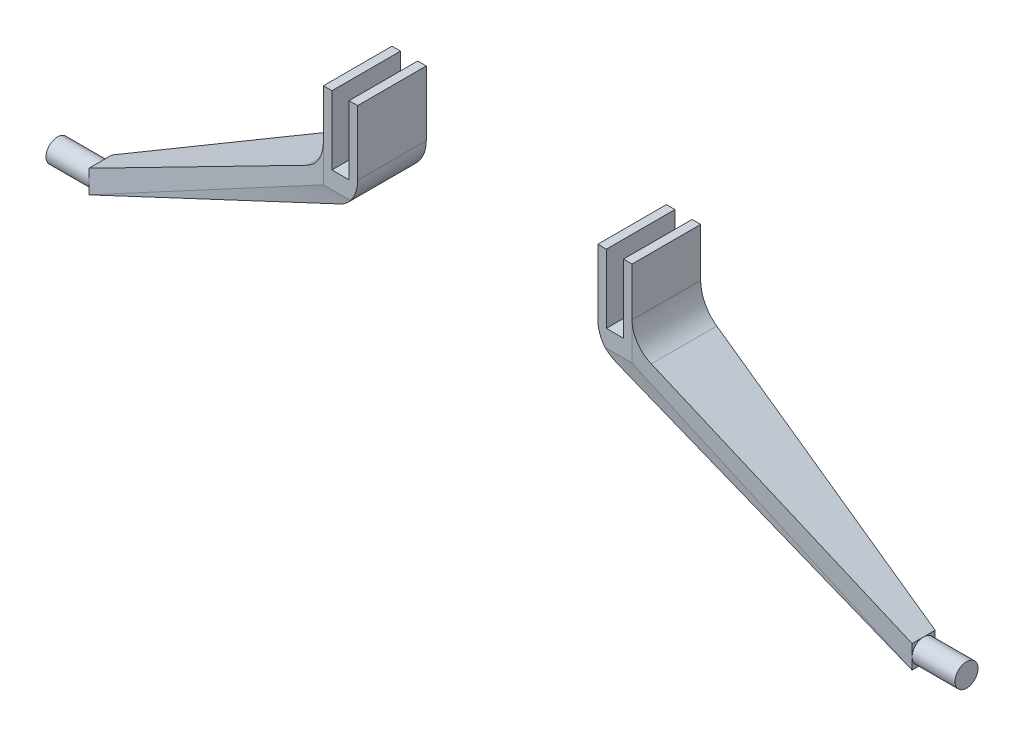
from build123d import *

# Parameters (mm, degrees)
BOSS_EXTRUDE1_DEPTH = 25.4
FILLET2_R           = 12.7
FILLET3_R           = 12.7
SKETCH7_R           = 4.2625
BOSS_EXTRUDE3_DEPTH = 15.875


with BuildPart() as part:
    # Sketch3 → Boss-Extrude1 (new body)
    with BuildSketch(Plane.XY):
        Polygon((-44.45, 50.8), (-44.45, 82.55), (-47.625, 82.55), (-47.625, 57.15), (-53.975, 57.15), (-53.975, 82.55), (-57.15, 82.55), (-57.15, 50.8), align=None)
    extrude(amount=BOSS_EXTRUDE1_DEPTH)

    # Sketch5 → section 1 of loft1
    with BuildSketch(Plane(origin=(-152.4, 0, 0), x_dir=(0, 0, -1), z_dir=(1, 0, 0)), mode=Mode.PRIVATE) as loft1_s1:
        with BuildLine():
            Line((-16.9625, 4.2625), (-8.4375, 4.2625))
            Line((-8.4375, 4.2625), (-8.4375, -4.2625))
            Line((-8.4375, -4.2625), (-16.9625, -4.2625))
            Line((-16.9625, -4.2625), (-16.9625, 4.2625))
        make_face()
    # loft from a face of the part (loft1)
    loft([part.faces().sort_by_distance((-50.8, 50.8, 12.7))[0], loft1_s1.sketch])

    # Sketch6 → Loft2 section 0
    with BuildSketch(Plane.ZY.offset(57.15)):
        with BuildLine():
            Line((0, 50.8), (25.4, 50.8))
            Line((25.4, 50.8), (25.4, 57.15))
            Line((25.4, 57.15), (0, 57.15))
            Line((0, 57.15), (0, 50.8))
        make_face()
    # Sketch5_2 → Loft2 section 1
    with BuildSketch(Plane(origin=(-152.4, 0, 0), x_dir=(0, 0, -1), z_dir=(1, 0, 0))):
        with BuildLine():
            Line((-16.9625, 4.2625), (-8.4375, 4.2625))
            Line((-8.4375, 4.2625), (-8.4375, -4.2625))
            Line((-8.4375, -4.2625), (-16.9625, -4.2625))
            Line((-16.9625, -4.2625), (-16.9625, 4.2625))
        make_face()
    loft()

    # Fillet2
    fillet2_edges = [part.edges().sort_by_distance(p)[0] for p in [
        (-57.15, 57.15, 12.7),
    ]]
    fillet(fillet2_edges, radius=FILLET2_R)

    # Fillet3
    fillet3_edges = [part.edges().sort_by_distance(p)[0] for p in [
        (-44.45, 50.8, 12.7),
    ]]
    fillet(fillet3_edges, radius=FILLET3_R)

    # Sketch7 → Boss-Extrude3 (add)
    with BuildSketch(Plane.ZY.offset(152.4)):
        with Locations((12.7, 0)):
            Circle(SKETCH7_R)
    extrude(amount=BOSS_EXTRUDE3_DEPTH)


with BuildPart() as body_2:
    # Mirror2: mirrored copy
    add(part.part.mirror(Plane(origin=(0, 0, 0), x_dir=(0, 0, 1), z_dir=(1, 0, 0))))


solid = Compound([part.part, body_2.part])
